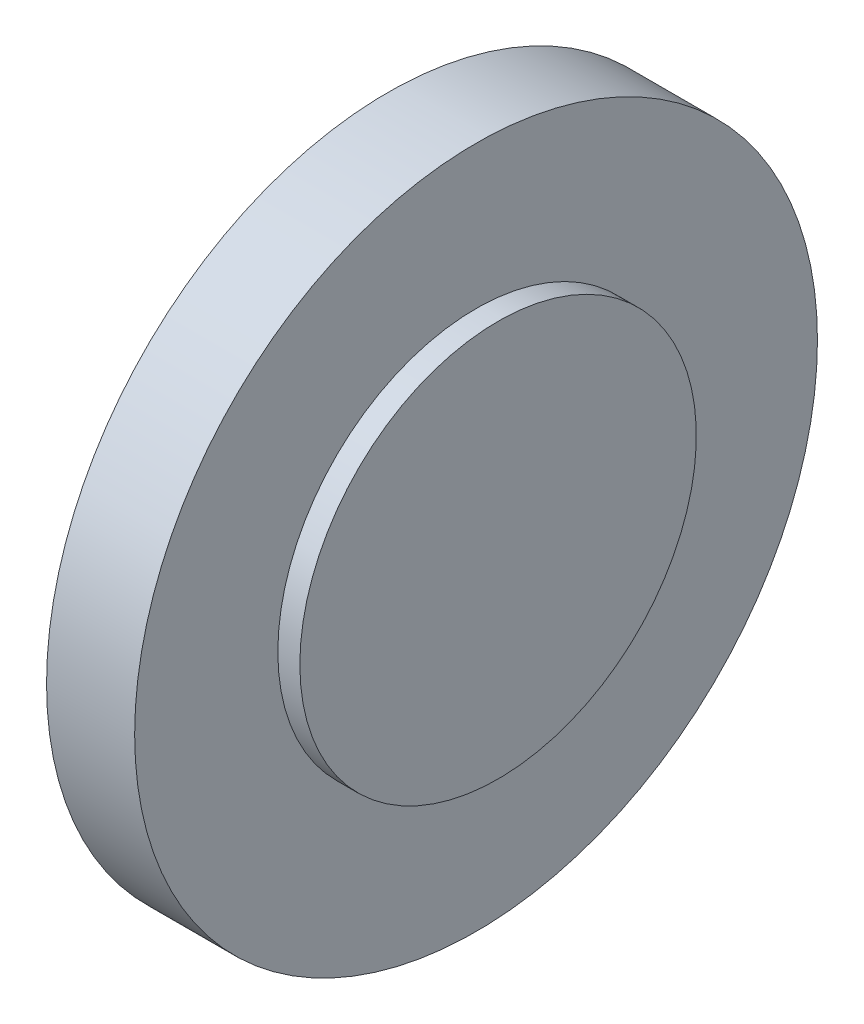
from build123d import *


with BuildPart() as part:
    # Sketch1 → Revolve1 (revolve)
    with BuildSketch(Plane.XY):
        Polygon((0, 0), (0, 46.5), (12, 46.5), (12, 27), (15, 27), (15, 0), align=None)
    revolve(axis=Axis((0, 0, 0), (1, 0, 0)))


solid = part.part
